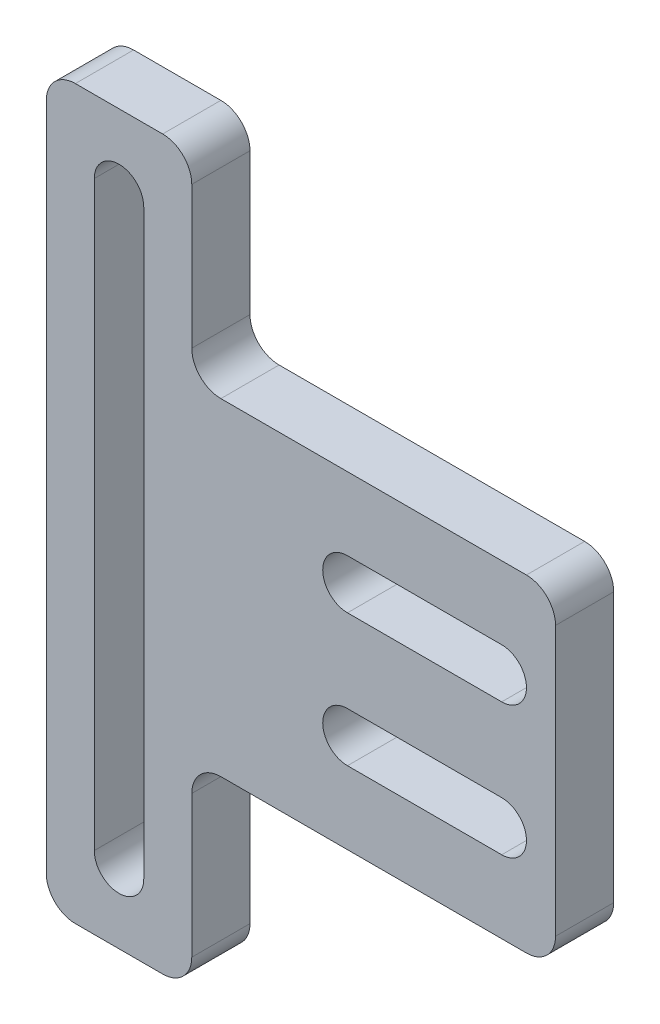
from build123d import *

# Parameters (mm, degrees)
BOSS_EXTRU_1_DEPTH = 2
CONG_1_R           = 2


with BuildPart() as part:
    # Esquisse1 → Boss.-Extru.1 (new body, symmetric)
    with BuildSketch(Plane.XY):
        Polygon((-17.5, -25), (-17.5, 25), (-7.5, 25), (-7.5, 11.25), (17.5, 11.25), (17.5, -11.25), (-7.5, -11.25), (-7.5, -25), align=None)
        with BuildLine():
            Line((3.2, 6.25), (13.8, 6.25))
            ThreePointArc((13.8, 6.25), (15.5, 4.55), (13.8, 2.85))
            Line((13.8, 2.85), (3.2, 2.85))
            ThreePointArc((3.2, 2.85), (1.5, 4.55), (3.2, 6.25))
        make_face(mode=Mode.SUBTRACT)
        with BuildLine():
            Line((3.2, -6.25), (13.8, -6.25))
            ThreePointArc((13.8, -6.25), (15.5, -4.55), (13.8, -2.85))
            Line((13.8, -2.85), (3.2, -2.85))
            ThreePointArc((3.2, -2.85), (1.5, -4.55), (3.2, -6.25))
        make_face(mode=Mode.SUBTRACT)
        with BuildLine():
            Line((-10.8, 20), (-10.8, -20))
            ThreePointArc((-10.8, -20), (-12.5, -21.7), (-14.2, -20))
            Line((-14.2, -20), (-14.2, 20))
            ThreePointArc((-14.2, 20), (-12.5, 21.7), (-10.8, 20))
        make_face(mode=Mode.SUBTRACT)
    extrude(amount=BOSS_EXTRU_1_DEPTH, both=True)

    # Congé1
    cong_1_edges = [part.edges().sort_by_distance(p)[0] for p in [
        (-17.5, -25, 0),
        (-17.5, 25, 0),
        (-7.5, 25, 0),
        (-7.5, 11.25, 0),
        (17.5, 11.25, 0),
        (17.5, -11.25, 0),
        (-7.5, -11.25, 0),
        (-7.5, -25, 0),
    ]]
    fillet(cong_1_edges, radius=CONG_1_R)


solid = part.part
